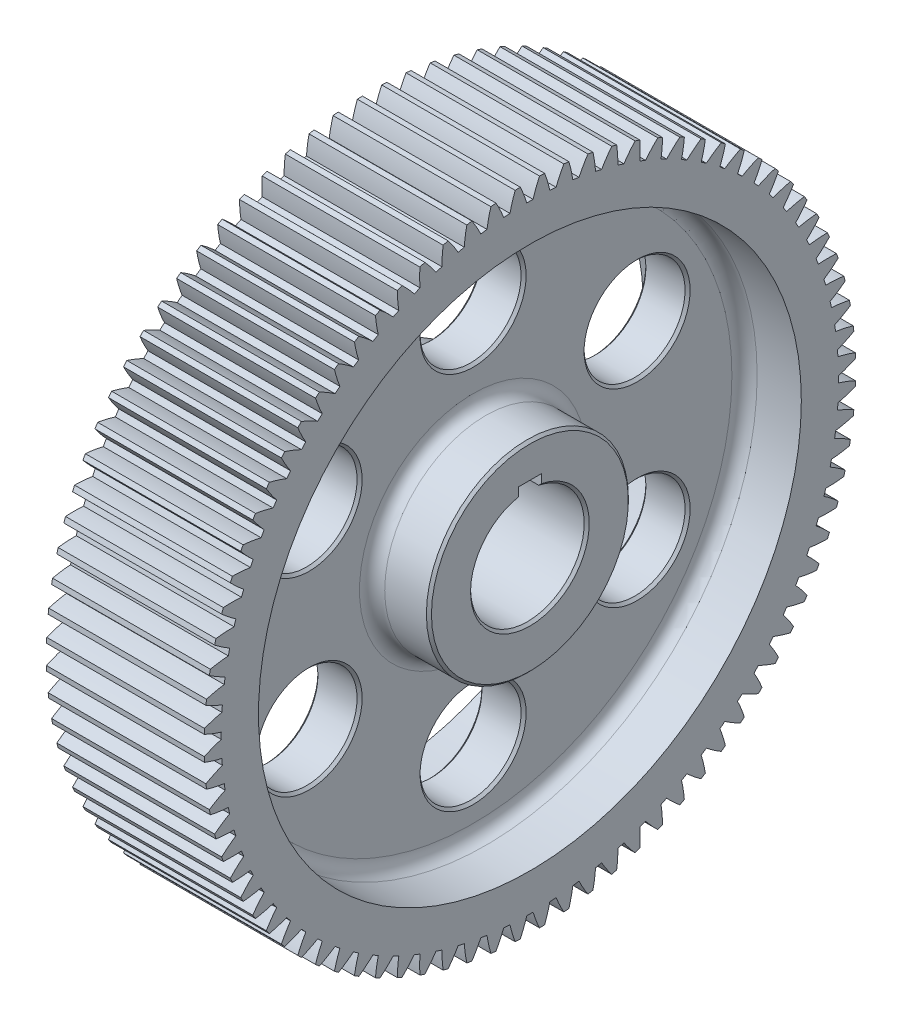
from build123d import *

# Parameters (mm, degrees)
BASPROSKE_W        = 125
BASPROSKE_H        = 258
TOOTHCUT_DEPTH     = 386.685104716
TEETHCUTS_COUNT    = 84
BORSKE_R           = 45
BORE_DEPTH         = 125
SKETCH1_R          = 215
SKETCH1_R_2        = 80
CUT_EXTRUDE1_DEPTH = 45
CUT_EXTRUDE2_START = -125
SKETCH1_2_R        = 215
SKETCH1_2_R_2      = 80
CUT_EXTRUDE2_DEPTH = 45
FILLET1_R          = 10
SKETCH2_R          = 40
SKETCH2_W          = 18
SKETCH2_H          = 16
CUT_EXTRUDE3_DEPTH = 386.534314407
CHAMFER1_SIZE      = 2


with BuildPart() as part:
    # BasProSke → Base-Revolve (revolve)
    with BuildSketch(Plane(origin=(0, 0, 0), x_dir=(1, 0, 0), z_dir=(0, 1, 0)), mode=Mode.PRIVATE) as base_revolve_sk:
        with Locations((62.5, 129)):
            Rectangle(BASPROSKE_W, BASPROSKE_H)
    revolve(base_revolve_sk.sketch.rotate(Axis((-10, 0, 0), (1, 0, 0)), 180), axis=Axis((-10, 0, 0), (1, 0, 0)))

    # TooCutSke → ToothCut (cut, through all)
    with BuildSketch(Plane(origin=(0, 0, 0), x_dir=(0, 0, -1), z_dir=(1, 0, 0))):
        with BuildLine():
            ThreePointArc((2.48084672, 244.48641353), (0, 244.499), (-2.48084672, 244.48641353))
            ThreePointArc((-2.48084672, 244.48641353), (-4.819219553, 251.291461554), (-7.637102755, 257.912352761))
            ThreePointArc((-7.637102755, 257.912352761), (0, 258.0254), (7.637102755, 257.912352761))
            ThreePointArc((7.637102755, 257.912352761), (4.819219553, 251.291461554), (2.48084672, 244.48641353))
        make_face()
    toothcut = extrude(amount=TOOTHCUT_DEPTH, mode=Mode.SUBTRACT)

    # TeethCuts: ToothCut ×84 about axis
    teethcuts_axis = Axis((0, 0, 0), (1, 0, 0))
    for i in range(1, TEETHCUTS_COUNT):
        add(toothcut.rotate(teethcuts_axis, i * 360 / TEETHCUTS_COUNT), mode=Mode.SUBTRACT)

    # BorSke → Bore (cut, symmetric)
    with BuildSketch(Plane(origin=(0, 0, 0), x_dir=(0, 0, -1), z_dir=(1, 0, 0))):
        with Locations(Location((0, 0, 0), (0, 0, 180))):
            Circle(BORSKE_R)
    extrude(amount=BORE_DEPTH, both=True, mode=Mode.SUBTRACT)

    # Sketch1 → Cut-Extrude1 (cut)
    with BuildSketch(Plane(origin=(125, 0, 0), x_dir=(0, 0, -1), z_dir=(1, 0, 0))):
        Circle(SKETCH1_R)
        Circle(SKETCH1_R_2, mode=Mode.SUBTRACT)
    extrude(amount=-CUT_EXTRUDE1_DEPTH, mode=Mode.SUBTRACT)

    # Sketch1_2 → Cut-Extrude2 (cut)
    with BuildSketch(Plane(origin=(125, 0, 0), x_dir=(0, 0, -1), z_dir=(1, 0, 0)).offset(CUT_EXTRUDE2_START)):
        Circle(SKETCH1_2_R)
        Circle(SKETCH1_2_R_2, mode=Mode.SUBTRACT)
    extrude(amount=CUT_EXTRUDE2_DEPTH, mode=Mode.SUBTRACT)

    # Fillet1
    fillet1_edges = [part.edges().sort_by_distance(p)[0] for p in [
        (80, 0, 215),
        (80, 0, 80),
        (45, 0, 215),
        (45, 0, 80),
    ]]
    fillet(fillet1_edges, radius=FILLET1_R)

    # Sketch2 → Cut-Extrude3 (cut, through all)
    with BuildSketch(Plane(origin=(125, 0, 0), x_dir=(0, 0, -1), z_dir=(1, 0, 0))):
        with Locations((0, 150)):
            Circle(SKETCH2_R)
        with Locations((129.903810568, 75)):
            Circle(SKETCH2_R)
        with Locations((129.903810568, -75)):
            Circle(SKETCH2_R)
        with Locations((0, -150)):
            Circle(SKETCH2_R)
        with Locations((-129.903810568, -75)):
            Circle(SKETCH2_R)
        with Locations((-129.903810568, 75)):
            Circle(SKETCH2_R)
        with Locations((0, 45)):
            Rectangle(SKETCH2_W, SKETCH2_H)
    extrude(amount=-CUT_EXTRUDE3_DEPTH, mode=Mode.SUBTRACT)

    # Chamfer1
    chamfer1_edges = [part.edges().sort_by_distance(p)[0] for p in [
        (125, 0, 80),
        (0, 0, 80),
        (0, -45, 0),
        (125, -45, 0),
        (80, 75, 169.903810568),
        (45, 75, 169.903810568),
        (80, -75, 169.903810568),
        (45, -75, 169.903810568),
        (80, -150, 40),
        (45, -150, 40),
        (80, -75, -89.903810568),
        (45, -75, -89.903810568),
        (80, 75, -89.903810568),
        (45, 75, -89.903810568),
        (80, 150, 40),
        (45, 150, 40),
    ]]
    chamfer(chamfer1_edges, length=CHAMFER1_SIZE)


solid = part.part
